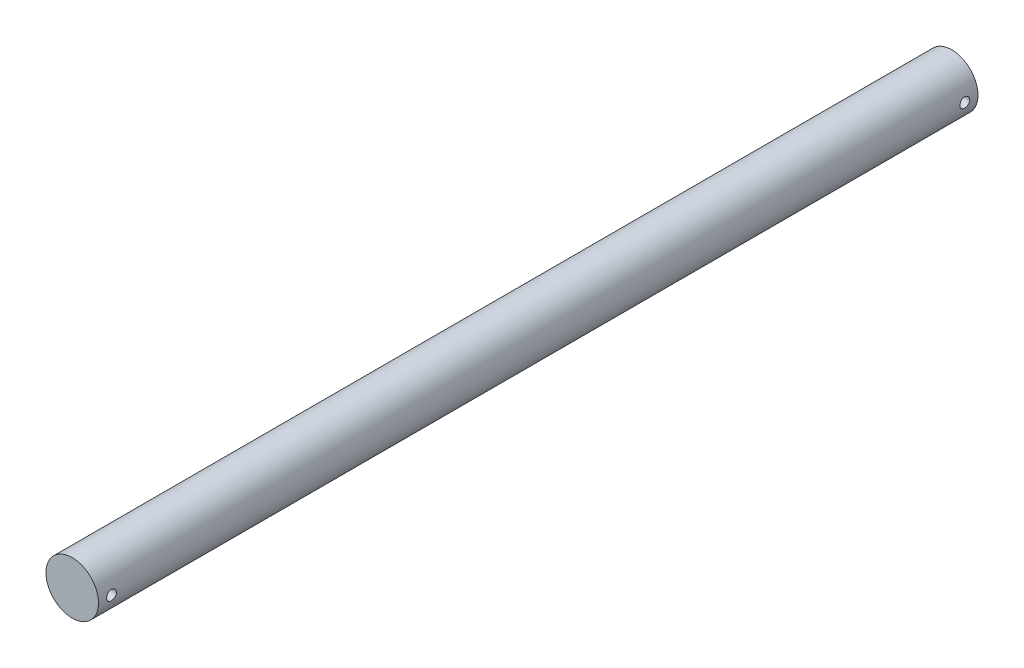
from build123d import *

# Parameters (mm, degrees)
SKETCH2_R               = 3.175
BOSS_EXTRUDE1_DEPTH     = 50
SKETCH3_R               = 3.175
BOSS_EXTRUDE2_DEPTH     = 3.175
SKETCH5_R               = 0.5953125
CUT_EXTRUDE1_DEPTH      = 4.175
CUT_EXTRUDE1_DEPTH_BACK = 4.175


with BuildPart() as part:
    # Sketch2 → Boss-Extrude1 (new body)
    with BuildSketch(Plane.XY):
        Circle(SKETCH2_R)
    boss_extrude1 = extrude(amount=BOSS_EXTRUDE1_DEPTH)

    # Sketch3 → Boss-Extrude2 (add)
    with BuildSketch(Plane.XY.offset(50)):
        Circle(SKETCH3_R)
    boss_extrude2 = extrude(amount=BOSS_EXTRUDE2_DEPTH)

    # Mirror1: Boss-Extrude1, Boss-Extrude2 across plane
    add(boss_extrude1.mirror(Plane.XY))
    add(boss_extrude2.mirror(Plane.XY))

    # Sketch5 → Cut-Extrude1 (cut, two sides)
    with BuildSketch(Plane(origin=(0, 0, 0), x_dir=(0, 0, -1), z_dir=(1, 0, 0))) as cut_extrude1_sk:
        with Locations((-51.5875, 0)):
            Circle(SKETCH5_R)
        with Locations((51.5875, 0)):
            Circle(SKETCH5_R)
    extrude(amount=CUT_EXTRUDE1_DEPTH, mode=Mode.SUBTRACT)
    extrude(cut_extrude1_sk.sketch, amount=-CUT_EXTRUDE1_DEPTH_BACK, mode=Mode.SUBTRACT)


solid = part.part
